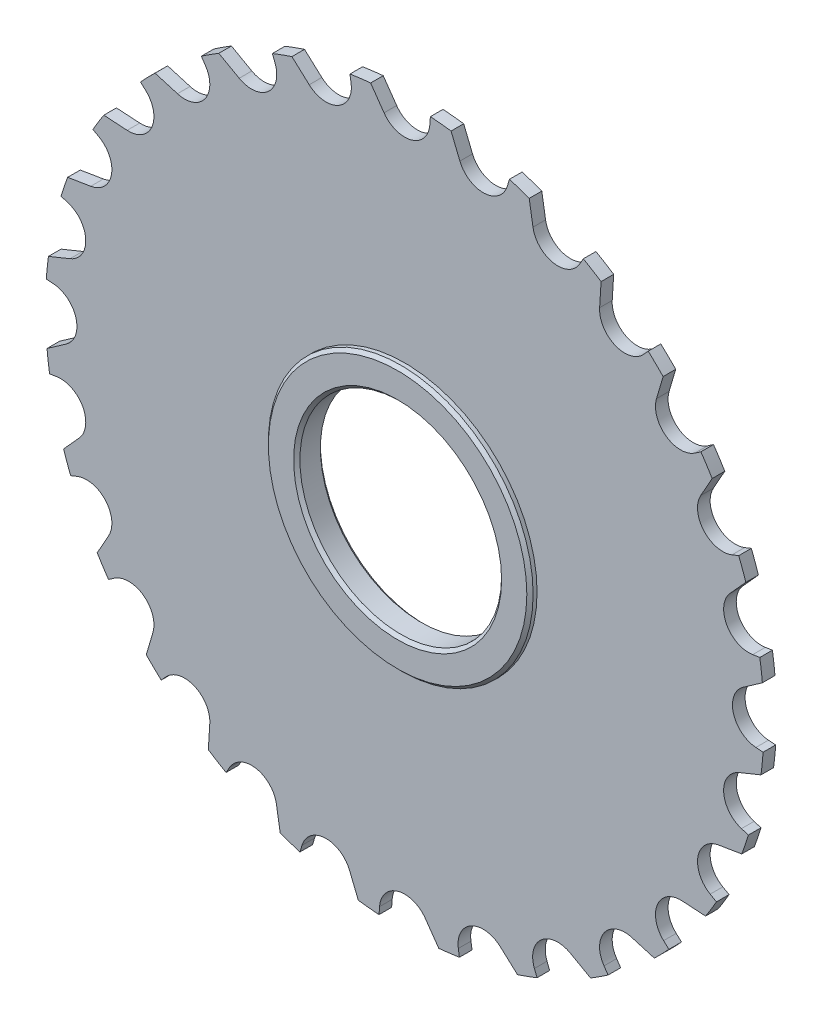
from build123d import *

# Parameters (mm, degrees)
ESQUISSE1_R                  = 57
EXTRUSION1_DEPTH             = 1
ENL_V_MAT_EXTRU_1_DEPTH      = 2
R_P_TITION_CIRCULAIRE1_COUNT = 28
ESQUISSE3_R                  = 21
EXTRUSION2_DEPTH             = 2.125
ESQUISSE4_R                  = 16
ENL_V_MAT_EXTRU_2_DEPTH      = 3.125
ENL_V_MAT_EXTRU_2_DEPTH_BACK = 3.125
CHANFREIN1_SIZE              = 0.5


with BuildPart() as part:
    # Esquisse1 → Extrusion1 (new body, symmetric)
    with BuildSketch(Plane.XY):
        Circle(ESQUISSE1_R)
    extrude(amount=EXTRUSION1_DEPTH, both=True)

    # Esquisse2 → Enlèv. mat.-Extru.1 (cut, symmetric)
    with BuildSketch(Plane.XY):
        with BuildLine():
            Line((-5.403559241, 56.743295177), (-3.276608177, 53.705694255))
            ThreePointArc((-3.276608177, 53.705694255), (1.065722501, 52.144583609), (3.98978287, 55.714285714))
            Line((3.98978287, 55.714285714), (4.071428571, 56.854405892))
            ThreePointArc((4.071428571, 56.854405892), (-0.668378207, 56.996081186), (-5.403559241, 56.743295177))
        make_face()
    enl_v_mat_extru_1 = extrude(amount=ENL_V_MAT_EXTRU_1_DEPTH, both=True, mode=Mode.SUBTRACT)

    # Répétition circulaire1: Enlèv. mat.-Extru.1 ×28 about axis
    r_p_tition_circulaire1_axis = Axis((0, 0, 0), (0, 0, 1))
    for i in range(1, R_P_TITION_CIRCULAIRE1_COUNT):
        add(enl_v_mat_extru_1.rotate(r_p_tition_circulaire1_axis, i * 360 / R_P_TITION_CIRCULAIRE1_COUNT), mode=Mode.SUBTRACT)

    # Esquisse3 → Extrusion2 (add, symmetric)
    with BuildSketch(Plane.XY):
        Circle(ESQUISSE3_R)
    extrude(amount=EXTRUSION2_DEPTH, both=True)

    # Esquisse4 → Enlèv. mat.-Extru.2 (cut, two sides)
    with BuildSketch(Plane.XY) as enl_v_mat_extru_2_sk:
        Circle(ESQUISSE4_R)
    extrude(amount=ENL_V_MAT_EXTRU_2_DEPTH, mode=Mode.SUBTRACT)
    extrude(enl_v_mat_extru_2_sk.sketch, amount=-ENL_V_MAT_EXTRU_2_DEPTH_BACK, mode=Mode.SUBTRACT)

    # Chanfrein1
    chanfrein1_edges = [part.edges().sort_by_distance(p)[0] for p in [
        (-21, 0, -2.125),
        (-21, 0, 2.125),
        (-16, 0, -2.125),
        (-16, 0, 2.125),
    ]]
    chamfer(chanfrein1_edges, length=CHANFREIN1_SIZE)


solid = part.part
